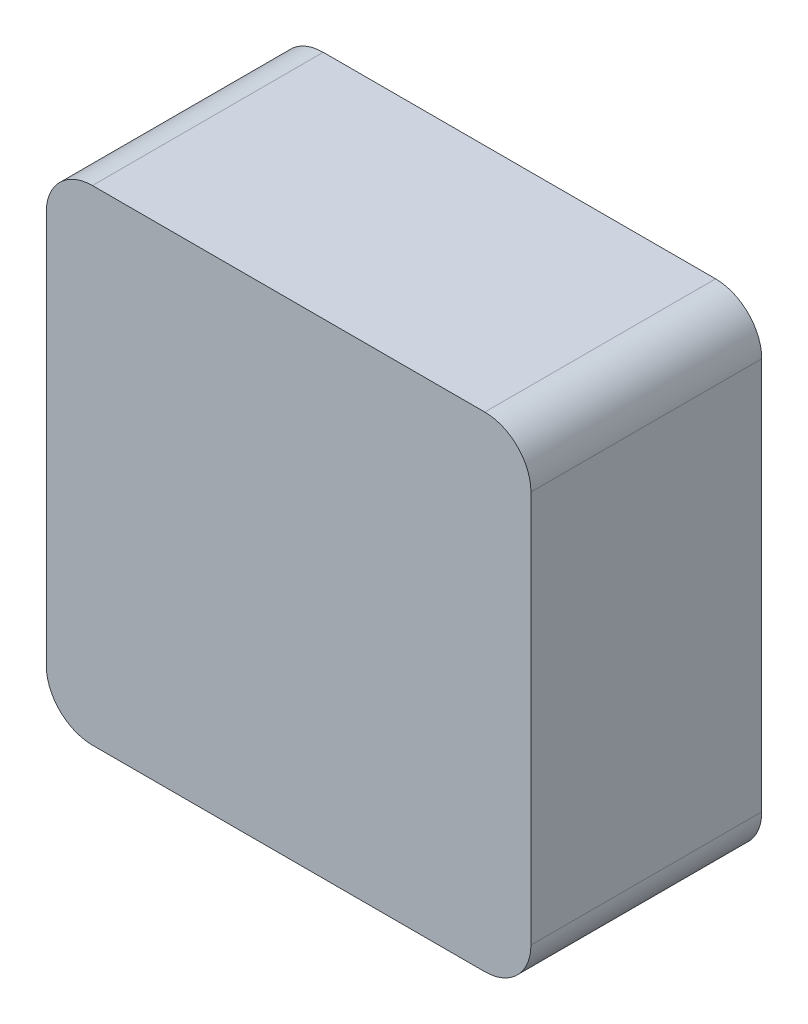
from build123d import *

# Parameters (mm, degrees)
SKETCH1_W           = 53.34
SKETCH1_H           = 25.4
BOSS_EXTRUDE1_DEPTH = 53.34
FILLET1_R           = 5.08
SKETCH2_W           = 40.64
SKETCH2_H           = 40.64
CUT_EXTRUDE1_DEPTH  = 17.78
FILLET2_R           = 5.08


with BuildPart() as part:
    # Sketch1 → Boss-Extrude1 (new body)
    with BuildSketch(Plane(origin=(0, 0, 0), x_dir=(1, 0, 0), z_dir=(0, 1, 0))):
        with Locations((26.67, 12.7)):
            Rectangle(SKETCH1_W, SKETCH1_H)
    extrude(amount=BOSS_EXTRUDE1_DEPTH)

    # Fillet1
    fillet1_edges = [part.edges().sort_by_distance(p)[0] for p in [
        (53.34, 53.34, -12.7),
        (0, 53.34, -12.7),
        (53.34, 0, -12.7),
        (0, 0, -12.7),
    ]]
    fillet(fillet1_edges, radius=FILLET1_R)

    # Sketch2 → Cut-Extrude1 (cut)
    with BuildSketch(Plane(origin=(0, 0, -25.4), x_dir=(-1, 0, 0), z_dir=(0, 0, -1))):
        with Locations((-26.67, 26.67)):
            Rectangle(SKETCH2_W, SKETCH2_H)
    extrude(amount=-CUT_EXTRUDE1_DEPTH, mode=Mode.SUBTRACT)

    # Fillet2
    fillet2_edges = [part.edges().sort_by_distance(p)[0] for p in [
        (46.99, 6.35, -16.51),
        (46.99, 46.99, -16.51),
        (6.35, 46.99, -16.51),
        (6.35, 6.35, -16.51),
    ]]
    fillet(fillet2_edges, radius=FILLET2_R)


solid = part.part
